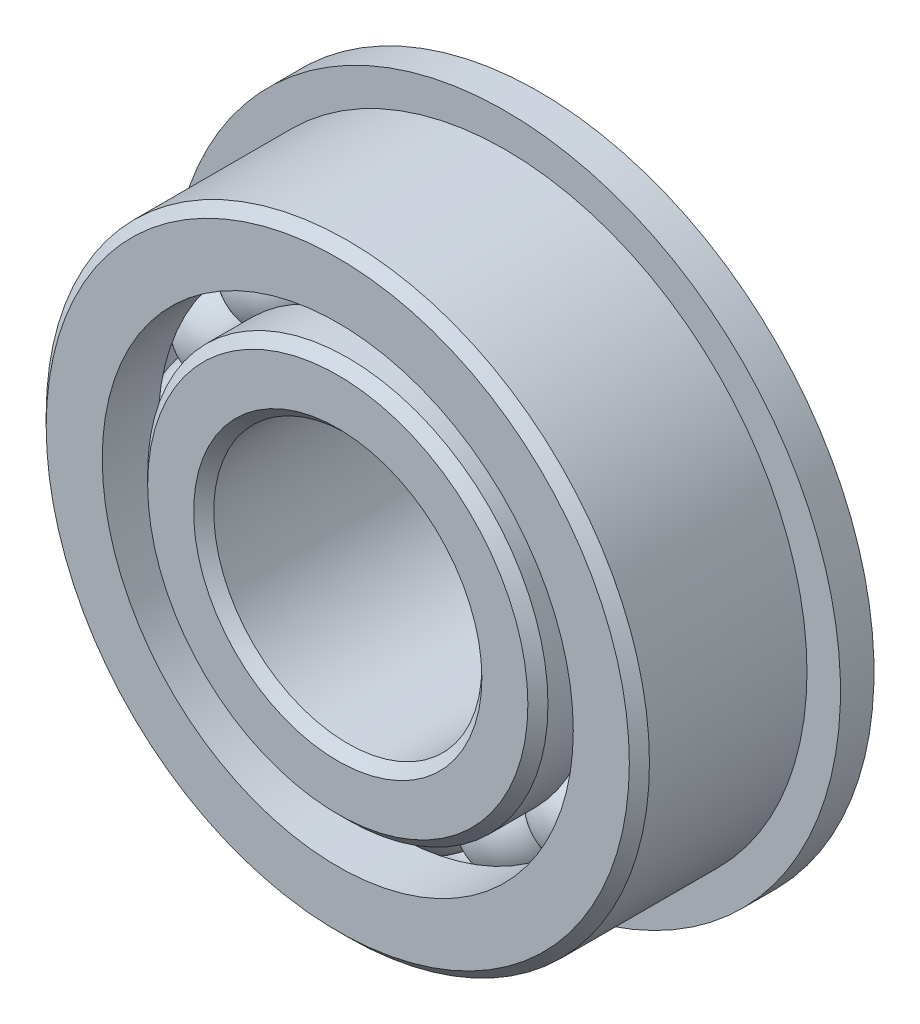
from build123d import *

# Parameters (mm, degrees)
CIRPATTERN1_COUNT = 16
SKETCH6_W         = 1.5875
SKETCH6_H         = 4.718887363


with BuildPart() as part:
    # Sketch1 → Revolve1 (revolve)
    with BuildSketch(Plane(origin=(0, 0, 0), x_dir=(0, 0, -1), z_dir=(1, 0, 0))):
        with BuildLine():
            Line((4.28625, 14.2875), (-4.28625, 14.2875))
            Line((-4.28625, 14.2875), (-4.7625, 13.81125))
            Line((-4.7625, 13.81125), (-4.7625, 11.156112637))
            Line((-4.7625, 11.156112637), (-2.116666667, 11.156112637))
            ThreePointArc((-2.116666667, 11.156112637), (0, 12.595030731), (2.116666667, 11.156112637))
            Line((2.116666667, 11.156112637), (4.7625, 11.156112637))
            Line((4.7625, 11.156112637), (4.7625, 13.81125))
            Line((4.7625, 13.81125), (4.28625, 14.2875))
        make_face()
    revolve(axis=Axis((0, 0, 4.7625), (0, 0, -1)))

    # Sketch6 → Revolve6 (revolve)
    with BuildSketch(Plane(origin=(0, 0, 0), x_dir=(0, 0, -1), z_dir=(1, 0, 0))):
        with Locations((3.96875, 13.515556319)):
            Rectangle(SKETCH6_W, SKETCH6_H)
    revolve(axis=Axis((0, 0, -4.7625), (0, 0, 1)))


with BuildPart() as body_2:
    # Sketch3 → Revolve3 (revolve)
    with BuildSketch(Plane(origin=(0, 0, 0), x_dir=(0, 0, -1), z_dir=(1, 0, 0))):
        with BuildLine():
            Line((-4.7625, 6.82625), (-4.7625, 9.005137363))
            Line((-4.7625, 9.005137363), (-4.28625, 9.481387363))
            Line((-4.28625, 9.481387363), (-2.116666667, 9.481387363))
            ThreePointArc((-2.116666667, 9.481387363), (0, 8.042469269), (2.116666667, 9.481387363))
            Line((2.116666667, 9.481387363), (5.87375, 9.481387363))
            Line((5.87375, 9.481387363), (6.35, 9.005137363))
            Line((6.35, 9.005137363), (6.35, 6.82625))
            Line((6.35, 6.82625), (5.87375, 6.35))
            Line((5.87375, 6.35), (-4.28625, 6.35))
            Line((-4.28625, 6.35), (-4.7625, 6.82625))
        make_face()
    revolve(axis=Axis((0, 0, 4.7625), (0, 0, -1)))


with BuildPart() as body_3:
    # Sketch4 → Revolve4 (revolve)
    with BuildSketch(Plane(origin=(0, 0, 0), x_dir=(0, 0, -1), z_dir=(1, 0, 0))):
        with BuildLine():
            Line((-2.276280731, 10.31875), (2.276280731, 10.31875))
            ThreePointArc((2.276280731, 10.31875), (0, 12.595030731), (-2.276280731, 10.31875))
        make_face()
    revolve(axis=Axis((0, 10.31875, 2.276280731), (0, 0, -1)))


with BuildPart() as cirpattern1_1:
    # CirPattern1: pattern copy
    add(body_3.part.rotate(Axis((0, 0, -4.7625), (0, 0, 1)), 1 * 360 / CIRPATTERN1_COUNT))


with BuildPart() as cirpattern1_2:
    # CirPattern1: pattern copy
    add(body_3.part.rotate(Axis((0, 0, -4.7625), (0, 0, 1)), 2 * 360 / CIRPATTERN1_COUNT))


with BuildPart() as cirpattern1_3:
    # CirPattern1: pattern copy
    add(body_3.part.rotate(Axis((0, 0, -4.7625), (0, 0, 1)), 3 * 360 / CIRPATTERN1_COUNT))


with BuildPart() as cirpattern1_4:
    # CirPattern1: pattern copy
    add(body_3.part.rotate(Axis((0, 0, -4.7625), (0, 0, 1)), 4 * 360 / CIRPATTERN1_COUNT))


with BuildPart() as cirpattern1_5:
    # CirPattern1: pattern copy
    add(body_3.part.rotate(Axis((0, 0, -4.7625), (0, 0, 1)), 5 * 360 / CIRPATTERN1_COUNT))


with BuildPart() as cirpattern1_6:
    # CirPattern1: pattern copy
    add(body_3.part.rotate(Axis((0, 0, -4.7625), (0, 0, 1)), 6 * 360 / CIRPATTERN1_COUNT))


with BuildPart() as cirpattern1_7:
    # CirPattern1: pattern copy
    add(body_3.part.rotate(Axis((0, 0, -4.7625), (0, 0, 1)), 7 * 360 / CIRPATTERN1_COUNT))


with BuildPart() as cirpattern1_8:
    # CirPattern1: pattern copy
    add(body_3.part.rotate(Axis((0, 0, -4.7625), (0, 0, 1)), 8 * 360 / CIRPATTERN1_COUNT))


with BuildPart() as cirpattern1_9:
    # CirPattern1: pattern copy
    add(body_3.part.rotate(Axis((0, 0, -4.7625), (0, 0, 1)), 9 * 360 / CIRPATTERN1_COUNT))


with BuildPart() as cirpattern1_10:
    # CirPattern1: pattern copy
    add(body_3.part.rotate(Axis((0, 0, -4.7625), (0, 0, 1)), 10 * 360 / CIRPATTERN1_COUNT))


with BuildPart() as cirpattern1_11:
    # CirPattern1: pattern copy
    add(body_3.part.rotate(Axis((0, 0, -4.7625), (0, 0, 1)), 11 * 360 / CIRPATTERN1_COUNT))


with BuildPart() as cirpattern1_12:
    # CirPattern1: pattern copy
    add(body_3.part.rotate(Axis((0, 0, -4.7625), (0, 0, 1)), 12 * 360 / CIRPATTERN1_COUNT))


with BuildPart() as cirpattern1_13:
    # CirPattern1: pattern copy
    add(body_3.part.rotate(Axis((0, 0, -4.7625), (0, 0, 1)), 13 * 360 / CIRPATTERN1_COUNT))


with BuildPart() as cirpattern1_14:
    # CirPattern1: pattern copy
    add(body_3.part.rotate(Axis((0, 0, -4.7625), (0, 0, 1)), 14 * 360 / CIRPATTERN1_COUNT))


with BuildPart() as cirpattern1_15:
    # CirPattern1: pattern copy
    add(body_3.part.rotate(Axis((0, 0, -4.7625), (0, 0, 1)), 15 * 360 / CIRPATTERN1_COUNT))


solid = Compound([part.part, body_2.part, body_3.part, cirpattern1_1.part, cirpattern1_2.part, cirpattern1_3.part, cirpattern1_4.part, cirpattern1_5.part, cirpattern1_6.part, cirpattern1_7.part, cirpattern1_8.part, cirpattern1_9.part, cirpattern1_10.part, cirpattern1_11.part, cirpattern1_12.part, cirpattern1_13.part, cirpattern1_14.part, cirpattern1_15.part])
